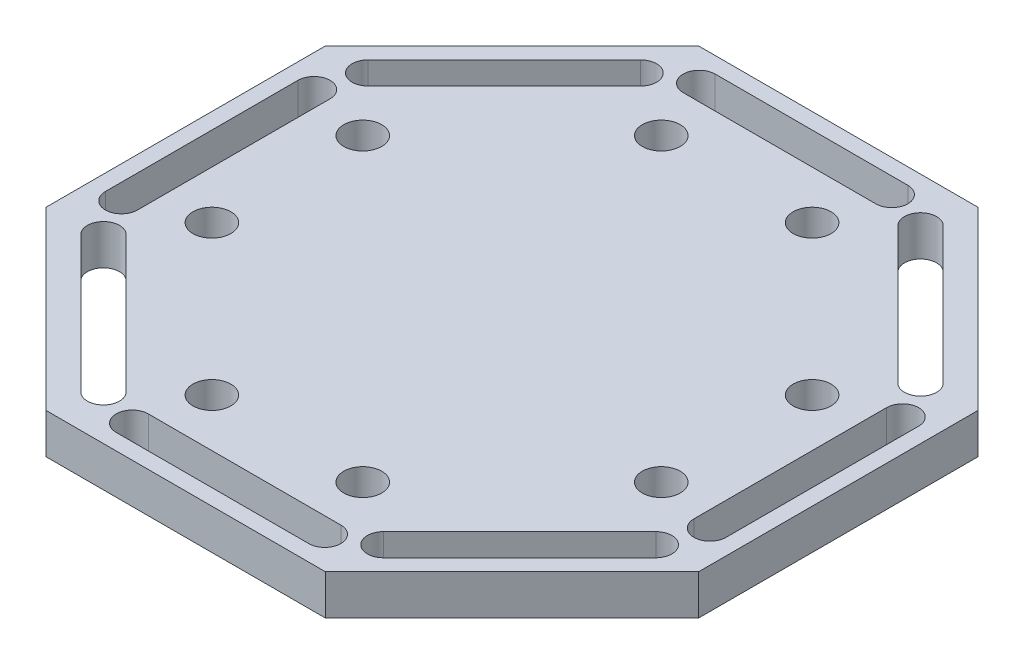
from build123d import *

# Parameters (mm, degrees)
SKETCH1_R           = 1.5
BOSS_EXTRUDE1_DEPTH = 3.175


with BuildPart() as part:
    # Sketch1 → Boss-Extrude1 (new body)
    with BuildSketch(Plane(origin=(0, 0, 0), x_dir=(1, 0, 0), z_dir=(0, 1, 0))):
        Polygon((-25.4, 10.621890813), (-25.4, -11.476109187), (-11.476109187, -25.4), (10.621890813, -25.4), (25.4, -10.621890813), (25.4, 11.476109187), (11.476109187, 25.4), (-10.621890813, 25.4), align=None)
        with Locations((-17.78, 5.969)):
            Circle(SKETCH1_R, mode=Mode.SUBTRACT)
        with Locations((-17.78, -5.969)):
            Circle(SKETCH1_R, mode=Mode.SUBTRACT)
        with Locations((-5.969, 17.78)):
            Circle(SKETCH1_R, mode=Mode.SUBTRACT)
        with Locations((5.969, 17.78)):
            Circle(SKETCH1_R, mode=Mode.SUBTRACT)
        with Locations((17.78, 5.969)):
            Circle(SKETCH1_R, mode=Mode.SUBTRACT)
        with Locations((17.78, -5.969)):
            Circle(SKETCH1_R, mode=Mode.SUBTRACT)
        with Locations((5.969, -17.78)):
            Circle(SKETCH1_R, mode=Mode.SUBTRACT)
        with Locations((-5.969, -17.78)):
            Circle(SKETCH1_R, mode=Mode.SUBTRACT)
        with BuildLine():
            Line((-24.13, -8.047109187), (-24.13, 7.192890813))
            ThreePointArc((-24.13, 7.192890813), (-22.86, 8.462890813), (-21.59, 7.192890813))
            Line((-21.59, 7.192890813), (-21.59, -8.047109187))
            ThreePointArc((-21.59, -8.047109187), (-22.86, -9.317109187), (-24.13, -8.047109187))
        make_face(mode=Mode.SUBTRACT)
        with BuildLine():
            Line((-20.956600881, 9.576269931), (-10.180293536, 20.352577276))
            ThreePointArc((-10.180293536, 20.352577276), (-10.180293536, 22.1486285), (-11.97634476, 22.1486285))
            Line((-11.97634476, 22.1486285), (-22.752652105, 11.372321155))
            ThreePointArc((-22.752652105, 11.372321155), (-22.752652105, 9.576269931), (-20.956600881, 9.576269931))
        make_face(mode=Mode.SUBTRACT)
        with BuildLine():
            Line((-8.047109187, 21.59), (7.192890813, 21.59))
            ThreePointArc((7.192890813, 21.59), (8.462890813, 22.86), (7.192890813, 24.13))
            Line((7.192890813, 24.13), (-8.047109187, 24.13))
            ThreePointArc((-8.047109187, 24.13), (-9.317109187, 22.86), (-8.047109187, 21.59))
        make_face(mode=Mode.SUBTRACT)
        with BuildLine():
            Line((9.576269931, 20.956600881), (20.352577276, 10.180293536))
            ThreePointArc((20.352577276, 10.180293536), (22.1486285, 10.180293536), (22.1486285, 11.97634476))
            Line((22.1486285, 11.97634476), (11.372321155, 22.752652105))
            ThreePointArc((11.372321155, 22.752652105), (9.576269931, 22.752652105), (9.576269931, 20.956600881))
        make_face(mode=Mode.SUBTRACT)
        with BuildLine():
            Line((21.59, 8.047109187), (21.59, -7.192890813))
            ThreePointArc((21.59, -7.192890813), (22.86, -8.462890813), (24.13, -7.192890813))
            Line((24.13, -7.192890813), (24.13, 8.047109187))
            ThreePointArc((24.13, 8.047109187), (22.86, 9.317109187), (21.59, 8.047109187))
        make_face(mode=Mode.SUBTRACT)
        with BuildLine():
            Line((20.956600881, -9.576269931), (10.180293536, -20.352577276))
            ThreePointArc((10.180293536, -20.352577276), (10.180293536, -22.1486285), (11.97634476, -22.1486285))
            Line((11.97634476, -22.1486285), (22.752652105, -11.372321155))
            ThreePointArc((22.752652105, -11.372321155), (22.752652105, -9.576269931), (20.956600881, -9.576269931))
        make_face(mode=Mode.SUBTRACT)
        with BuildLine():
            Line((8.047109187, -21.59), (-7.192890813, -21.59))
            ThreePointArc((-7.192890813, -21.59), (-8.462890813, -22.86), (-7.192890813, -24.13))
            Line((-7.192890813, -24.13), (8.047109187, -24.13))
            ThreePointArc((8.047109187, -24.13), (9.317109187, -22.86), (8.047109187, -21.59))
        make_face(mode=Mode.SUBTRACT)
        with BuildLine():
            Line((-9.576269931, -20.956600881), (-20.352577276, -10.180293536))
            ThreePointArc((-20.352577276, -10.180293536), (-22.1486285, -10.180293536), (-22.1486285, -11.97634476))
            Line((-22.1486285, -11.97634476), (-11.372321155, -22.752652105))
            ThreePointArc((-11.372321155, -22.752652105), (-9.576269931, -22.752652105), (-9.576269931, -20.956600881))
        make_face(mode=Mode.SUBTRACT)
    extrude(amount=BOSS_EXTRUDE1_DEPTH)


solid = part.part
